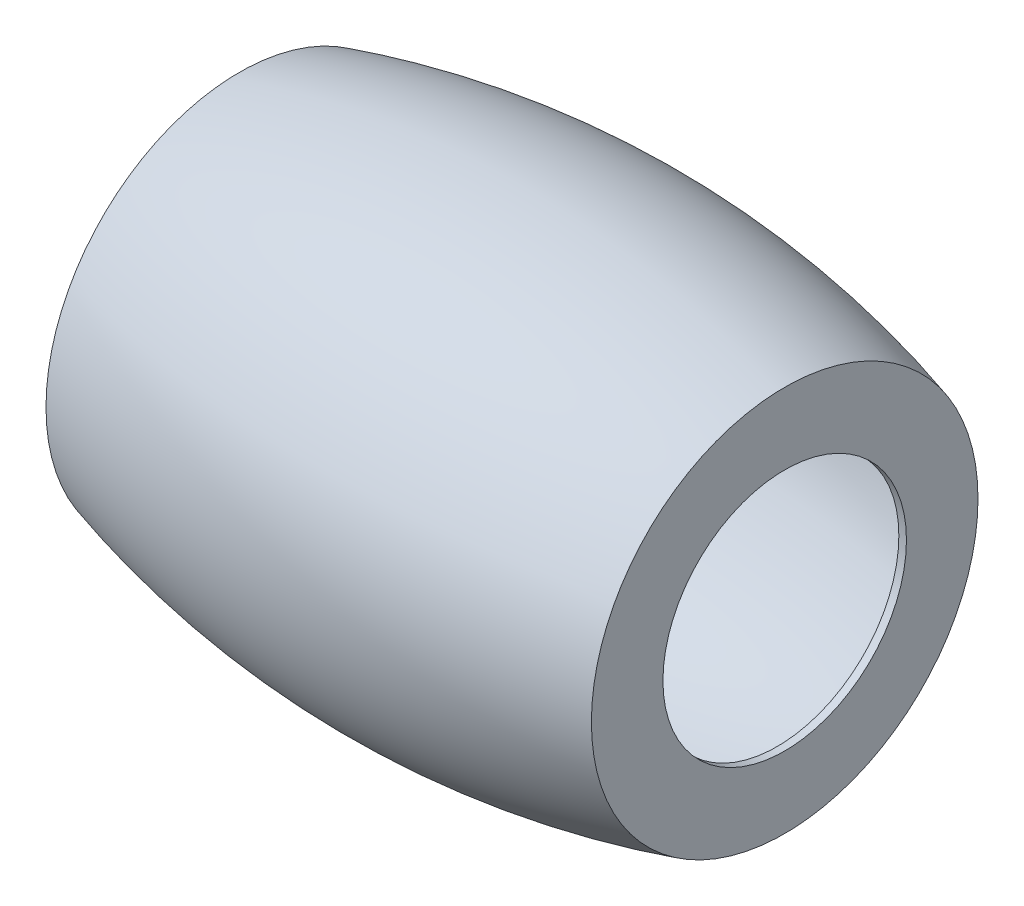
from build123d import *


with BuildPart() as part:
    # Sketch2 → Revolve1 (revolve)
    with BuildSketch(Plane.XY):
        with BuildLine():
            Line((-17.916428128, 8), (-17.916428128, 12.7))
            ThreePointArc((-17.916428128, 12.7), (0, 15.217989764), (17.916428128, 12.7))
            Line((17.916428128, 12.7), (17.916428128, 8))
            Line((17.916428128, 8), (17.416428128, 8))
            Line((17.416428128, 8), (17.416428128, 12.322080058))
            ThreePointArc((17.416428128, 12.322080058), (0, 14.717989764), (-17.416428128, 12.322080058))
            Line((-17.416428128, 12.322080058), (-17.416428128, 8))
            Line((-17.416428128, 8), (-17.916428128, 8))
        make_face()
    revolve(axis=Axis((17.916428128, 0, 0), (-1, 0, 0)))


solid = part.part
